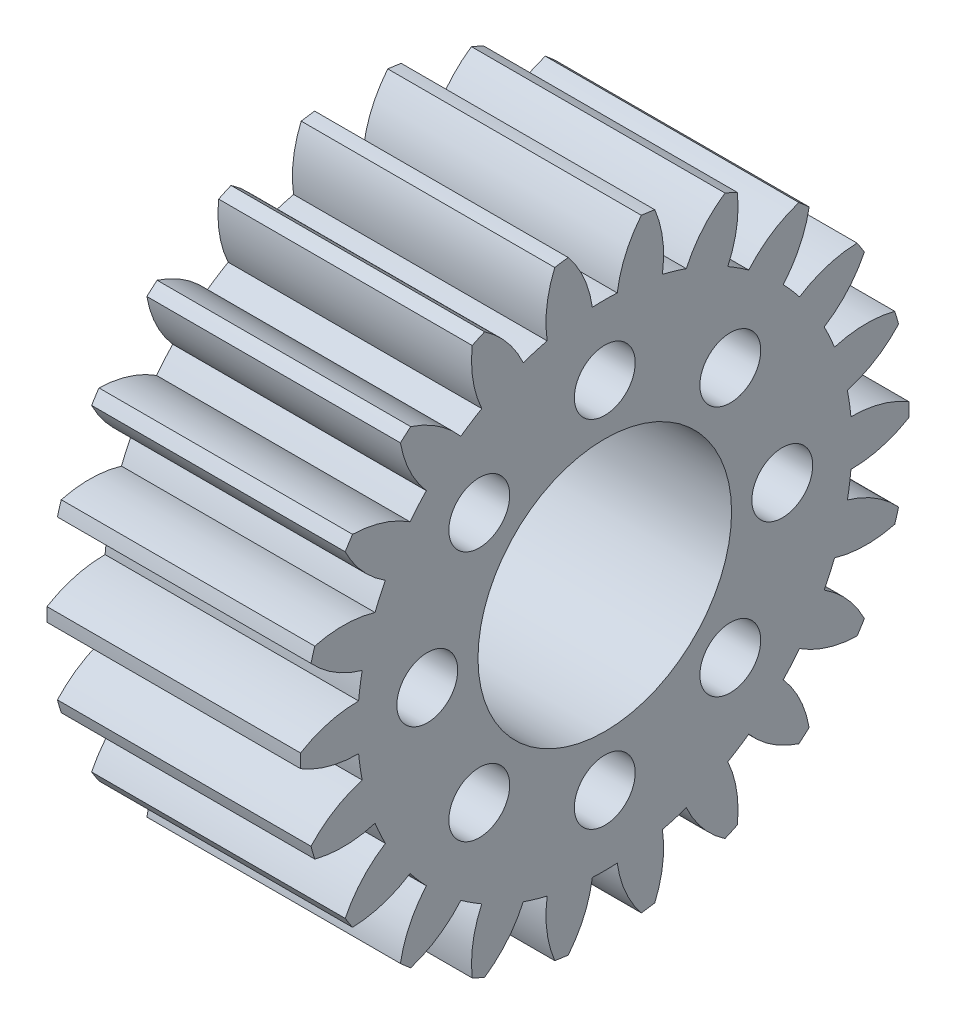
from build123d import *

# Parameters (mm, degrees)
BASPROSKE_W          = 10
BASPROSKE_H          = 12
TOOTHCUT_DEPTH       = 20.697715604
TEETHCUTS_COUNT      = 22
TEETHCUTS_ANGLE      = 343.636363636
BORSKE_R             = 5
BORE_DEPTH           = 50.0000508
D_GAGEMENT_M21_D     = 2.4
D_GAGEMENT_M21_DEPTH = 10


with BuildPart() as part:
    # BasProSke → Base-Revolve (revolve)
    with BuildSketch(Plane(origin=(0, 0, 0), x_dir=(1, 0, 0), z_dir=(0, 1, 0)), mode=Mode.PRIVATE) as base_revolve_sk:
        with Locations((5, 6)):
            Rectangle(BASPROSKE_W, BASPROSKE_H)
    revolve(base_revolve_sk.sketch.rotate(Axis((-10, 0, 0), (1, 0, 0)), 180), axis=Axis((-10, 0, 0), (1, 0, 0)))

    # TooCutSke → ToothCut (cut, through all)
    with BuildSketch(Plane(origin=(0, 0, 0), x_dir=(0, 0, -1), z_dir=(1, 0, 0))):
        with BuildLine():
            ThreePointArc((0.491001901, 9.736627657), (0, 9.749), (-0.491001901, 9.736627657))
            ThreePointArc((-0.491001901, 9.736627657), (-0.822824844, 10.904005344), (-1.46093845, 11.936327074))
            ThreePointArc((-1.46093845, 11.936327074), (0, 12.0254), (1.46093845, 11.936327074))
            ThreePointArc((1.46093845, 11.936327074), (0.822824844, 10.904005344), (0.491001901, 9.736627657))
        make_face()
    toothcut = extrude(amount=TOOTHCUT_DEPTH, mode=Mode.SUBTRACT)

    # TeethCuts: ToothCut ×22 about axis
    teethcuts_axis = Axis((-10, 0, 0), (1, 0, 0))
    for i in range(1, TEETHCUTS_COUNT):
        add(toothcut.rotate(teethcuts_axis, i * TEETHCUTS_ANGLE / (TEETHCUTS_COUNT - 1)), mode=Mode.SUBTRACT)

    # BorSke → Bore (cut, symmetric)
    with BuildSketch(Plane(origin=(0, 0, 0), x_dir=(0, 0, -1), z_dir=(1, 0, 0))):
        with Locations(Location((0, 0, 0), (0, 0, 180))):
            Circle(BORSKE_R)
    extrude(amount=BORE_DEPTH, both=True, mode=Mode.SUBTRACT)

    # Dégagement M21
    with Locations(Plane(origin=(10, 0, 0), x_dir=(0, 0, -1), z_dir=(1, 0, 0))):
        with Locations((0, 7), (4.949747468, 4.949747468), (7, 0), (4.949747468, -4.949747468), (0, -7), (-4.949747468, -4.949747468), (-7, 0), (-4.949747468, 4.949747468), (0, 0)):
            Hole(D_GAGEMENT_M21_D / 2, depth=D_GAGEMENT_M21_DEPTH)


solid = part.part
